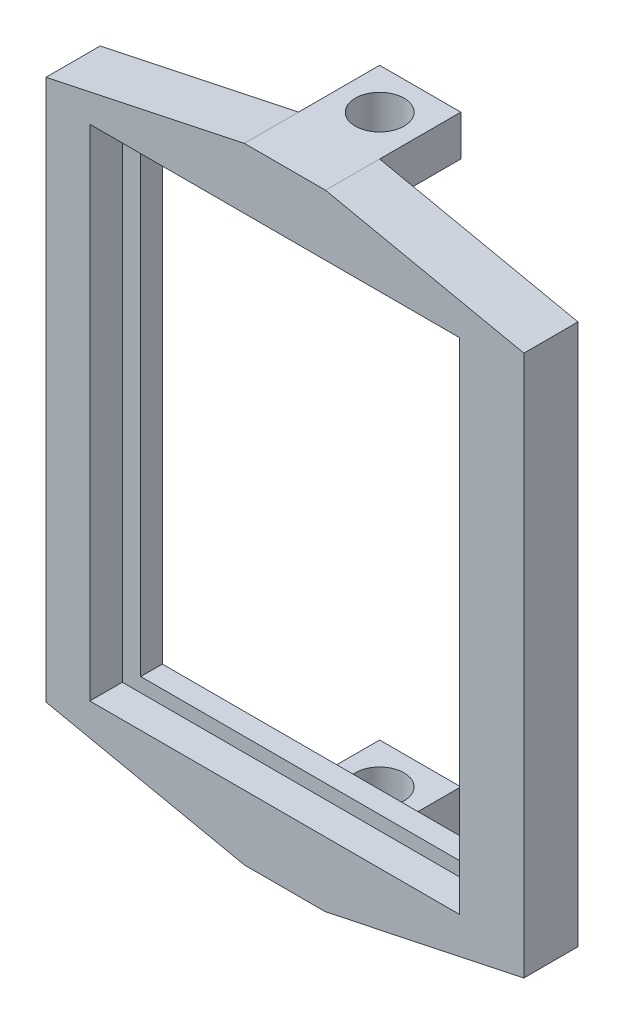
from build123d import *

# Parameters (mm, degrees)
ESQUISSE1_W             = 7.5
ESQUISSE1_H             = 3.75
BOSS_EXTRU_1_DEPTH      = 7.5
BOSS_EXTRU_1_2_DEPTH    = 7.5
ESQUISSE2_R             = 2.25
ENL_V_MAT_EXTRU_1_DEPTH = 58.737772997
ESQUISSE4_W             = 31.7
ESQUISSE4_H             = 43.35
BOSS_EXTRU_2_DEPTH      = 2
ESQUISSE5_W             = 34.15
ESQUISSE5_H             = 46.15
BOSS_EXTRU_3_DEPTH      = 3


with BuildPart() as part:
    # Esquisse1 → Boss.-Extru.1 (new body)
    with BuildSketch(Plane.XY):
        with Locations((6.831943462, 26.473190482)):
            Rectangle(ESQUISSE1_W, ESQUISSE1_H)
    extrude(amount=BOSS_EXTRU_1_DEPTH)


with BuildPart() as body_2:
    # Esquisse1 → Boss.-Extru.1 2 (new body)
    with BuildSketch(Plane.XY):
        with Locations((6.831943462, -27.514582515)):
            Rectangle(ESQUISSE1_W, ESQUISSE1_H)
    extrude(amount=BOSS_EXTRU_1_2_DEPTH)


with BuildPart() as enl_v_mat_extru_1_tool:
    # Esquisse2 → Enlèv. mat.-Extru.1 (new body, through all)
    with BuildSketch(Plane(origin=(0, 28.348190482, 0), x_dir=(1, 0, 0), z_dir=(0, 1, 0))):
        with Locations((6.831943462, -3.75)):
            Circle(ESQUISSE2_R)
    extrude(amount=-ENL_V_MAT_EXTRU_1_DEPTH)


with BuildPart() as part_1:
    add(part.part)

    # Enlèv. mat.-Extru.1: cut by enl_v_mat_extru_1_tool
    add(enl_v_mat_extru_1_tool.part, mode=Mode.SUBTRACT)



with BuildPart() as body_2_1:
    add(body_2.part)

    # Enlèv. mat.-Extru.1: cut by enl_v_mat_extru_1_tool
    add(enl_v_mat_extru_1_tool.part, mode=Mode.SUBTRACT)


with BuildPart() as part_2:
    add(part_1.part)

    add(body_2_1.part)  # Boss.-Extru.2 merges body 2
    # Esquisse4 → Boss.-Extru.2 (add)
    with BuildSketch(Plane.XY.offset(7.5)):
        Polygon((-15.243056538, 24.478190482), (-15.243056538, -25.521809518), (3.081943462, -29.389582515), (10.581943462, -29.389582515), (28.906943461, -25.521809518), (28.906943461, 24.478190482), (10.581943462, 28.348190482), (3.081943462, 28.348190482), align=None)
        with Locations((6.356943462, -0.426809518)):
            Rectangle(ESQUISSE4_W, ESQUISSE4_H, mode=Mode.SUBTRACT)
    extrude(amount=BOSS_EXTRU_2_DEPTH)

    # Esquisse5 → Boss.-Extru.3 (add)
    with BuildSketch(Plane.XY.offset(9.5)):
        Polygon((-15.243056538, 24.478190482), (3.081943462, 28.348190482), (10.581943462, 28.348190482), (28.906943461, 24.478190482), (28.906943461, -25.521809518), (10.581943462, -29.389582515), (3.081943462, -29.389582515), (-15.243056538, -25.521809518), align=None)
        with Locations((5.881943462, -0.331809518)):
            Rectangle(ESQUISSE5_W, ESQUISSE5_H, mode=Mode.SUBTRACT)
    extrude(amount=BOSS_EXTRU_3_DEPTH)


solid = part_2.part
